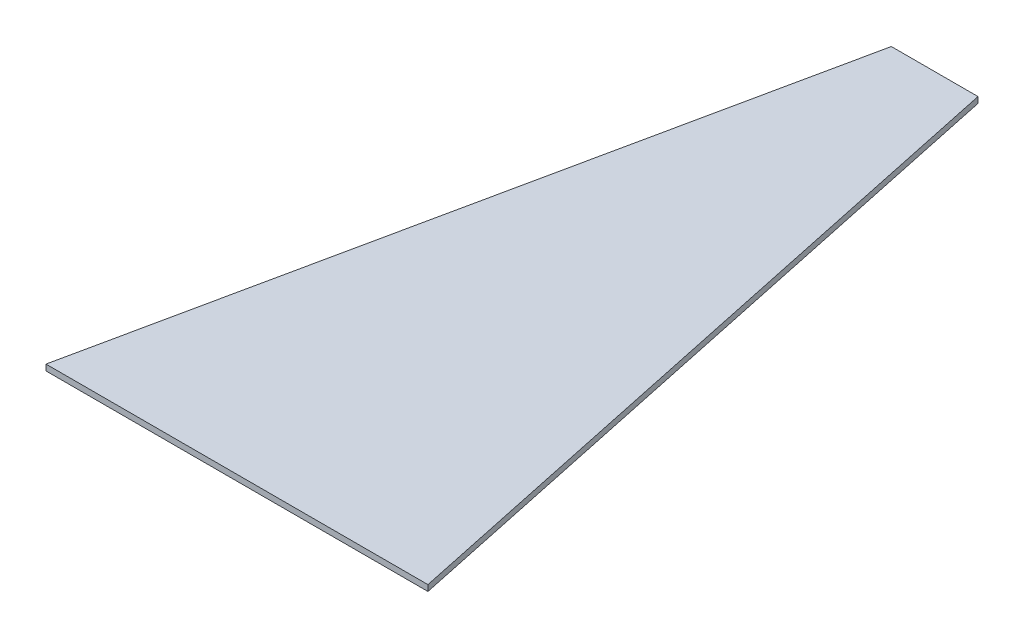
from build123d import *

# Parameters (mm, degrees)
BOSS_EXTRU_1_DEPTH = 2


with BuildPart() as part:
    # Esquisse1 → Boss.-Extru.1 (new body)
    with BuildSketch(Plane(origin=(0, 0, 0), x_dir=(1, 0, 0), z_dir=(0, 1, 0))):
        Polygon((78.53773978, 233.863594462), (49.486830816, 233.863594462), (0, 0), (128.024570597, 0), align=None)
    extrude(amount=BOSS_EXTRU_1_DEPTH)


solid = part.part
